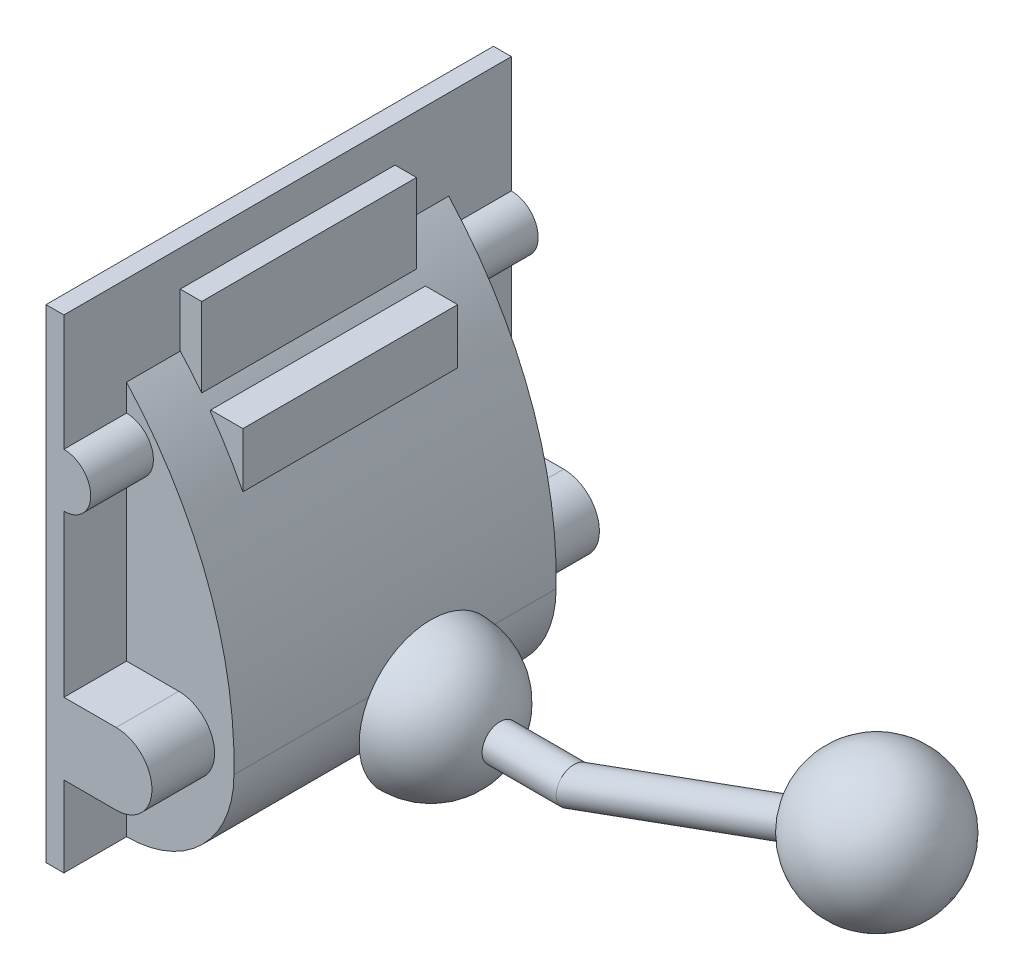
from build123d import *

# Parameters (mm, degrees)
BOSS_EXTRUDE1_DEPTH = 90
SKETCH2_W           = 250
SKETCH2_H           = 270
BOSS_EXTRUDE2_DEPTH = 10
SKETCH4_W           = 12
SKETCH4_H           = 72.929709738
SKETCH4_W_2         = 18
SKETCH4_H_2         = 62.633795367
BOSS_EXTRUDE3_DEPTH = 60
BOSS_EXTRUDE4_DEPTH = 250
SKETCH6_R           = 10
BOSS_EXTRUDE5_DEPTH = 160
SKETCH9_R           = 10


with BuildPart() as part:
    # Sketch1 → Boss-Extrude1 (new body, symmetric)
    with BuildSketch(Plane.XY):
        with BuildLine():
            Line((0, 0), (0, 220))
            ThreePointArc((0, 220), (45.41051287, 145.778942326), (60, 60))
            ThreePointArc((60, 60), (42.426406871, 17.573593129), (0, 0))
        make_face()
    extrude(amount=BOSS_EXTRUDE1_DEPTH, both=True)

    # Sketch2 → Boss-Extrude2 (add)
    with BuildSketch(Plane.ZY):
        with Locations((0, 135)):
            Rectangle(SKETCH2_W, SKETCH2_H)
    extrude(amount=BOSS_EXTRUDE2_DEPTH)

    # Sketch4 → Boss-Extrude3 (add, symmetric)
    with BuildSketch(Plane.XY):
        with Locations((6, 213.535145131)):
            Rectangle(SKETCH4_W, SKETCH4_H)
        with Locations((26, 168.683102316)):
            Rectangle(SKETCH4_W_2, SKETCH4_H_2)
    extrude(amount=BOSS_EXTRUDE3_DEPTH, both=True)

    # Sketch5 → Boss-Extrude4 (add)
    with BuildSketch(Plane.XY.offset(125)):
        with BuildLine():
            Line((0, 85), (29.195094319, 85))
            ThreePointArc((29.195094319, 85), (49.195094319, 65), (29.195094319, 45))
            Line((29.195094319, 45), (0, 45))
            Line((0, 45), (0, 85))
        make_face()
        with BuildLine():
            Line((0, 205), (0, 175))
            ThreePointArc((0, 175), (15, 190), (0, 205))
        make_face()
    extrude(amount=-BOSS_EXTRUDE4_DEPTH)

    # Sketch6 → Boss-Extrude5 (add)
    with BuildSketch(Plane(origin=(0, 0, 0), x_dir=(0, 0, -1), z_dir=(1, 0, 0))):
        with Locations((0, 60)):
            Circle(SKETCH6_R)
    extrude(amount=BOSS_EXTRUDE5_DEPTH)

    # Sweep1: sweep along a path in Sketch8
    with BuildLine(Plane.XY) as sweep1_path:
        Line((160, 60), (329.144671741, 121.563625799))
    # Sketch9 → Sweep1 (sweep)
    with BuildSketch(Plane(origin=(160, 0, 0), x_dir=(0, 0, -1), z_dir=(1, 0, 0))):
        with Locations((0, 60)):
            Circle(SKETCH9_R)
    sweep(path=sweep1_path.line)


with BuildPart() as body_2:
    # Sketch7 → Revolve1 (revolve)
    with BuildSketch(Plane(origin=(0, 60, 0), x_dir=(-1, 0, 0), z_dir=(0, -1, 0))):
        with BuildLine():
            Line((-80, 0), (-80, -40))
            ThreePointArc((-80, -40), (-108.284271247, -28.284271247), (-120, 0))
            Line((-120, 0), (-80, 0))
        make_face()
    revolve(axis=Axis((120, 60, 0), (-1, 0, 0)))


with BuildPart() as body_3:
    # Sketch10 → Revolve2 (revolve)
    with BuildSketch(Plane.XY):
        with BuildLine():
            Line((329.144671741, 161.563625799), (329.144671741, 81.563625799))
            ThreePointArc((329.144671741, 81.563625799), (369.144671741, 121.563625799), (329.144671741, 161.563625799))
        make_face()
    revolve(axis=Axis((329.144671741, 161.563625799, 0), (0, -1, 0)))


solid = Compound([part.part, body_2.part, body_3.part])
